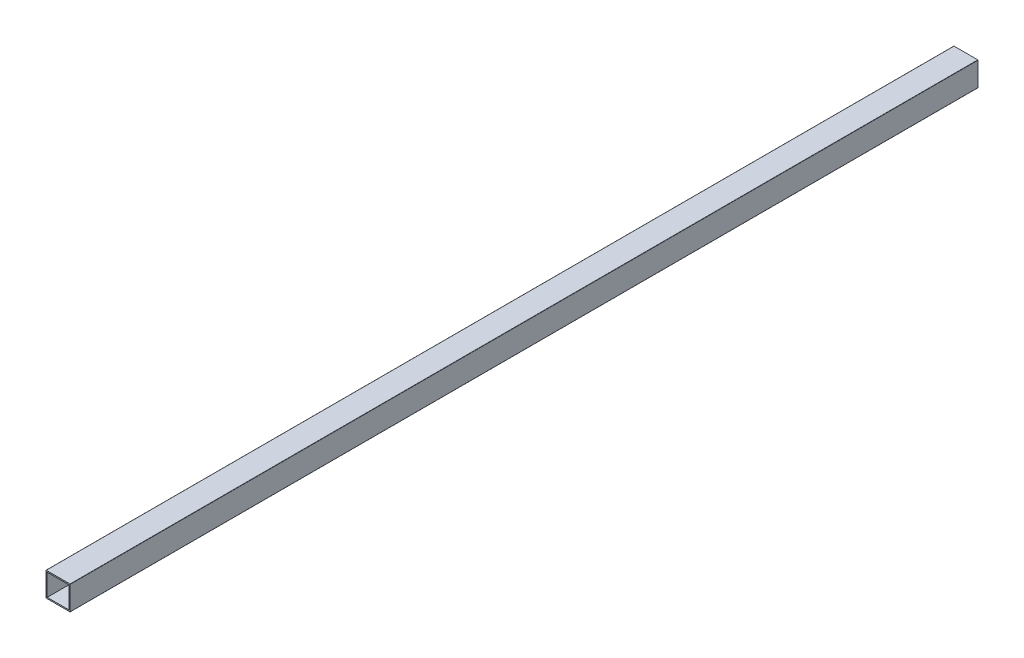
from build123d import *

# Parameters (mm, degrees)
SKETCH1_W           = 18
SKETCH1_H           = 18
BOSS_EXTRUDE1_DEPTH = 750


with BuildPart() as part:
    # Sketch1 → Boss-Extrude1 (new body)
    with BuildSketch(Plane.XY):
        with BuildLine():
            Line((0.2, 0), (19.8, 0))
            ThreePointArc((19.8, 0), (19.941421356, 0.058578644), (20, 0.2))
            Line((20, 0.2), (20, 19.8))
            ThreePointArc((20, 19.8), (19.941421356, 19.941421356), (19.8, 20))
            Line((19.8, 20), (0.2, 20))
            ThreePointArc((0.2, 20), (0.058578644, 19.941421356), (0, 19.8))
            Line((0, 19.8), (0, 0.2))
            ThreePointArc((0, 0.2), (0.058578644, 0.058578644), (0.2, 0))
        make_face()
        with Locations((10, 10)):
            Rectangle(SKETCH1_W, SKETCH1_H, mode=Mode.SUBTRACT)
    extrude(amount=BOSS_EXTRUDE1_DEPTH)


solid = part.part
